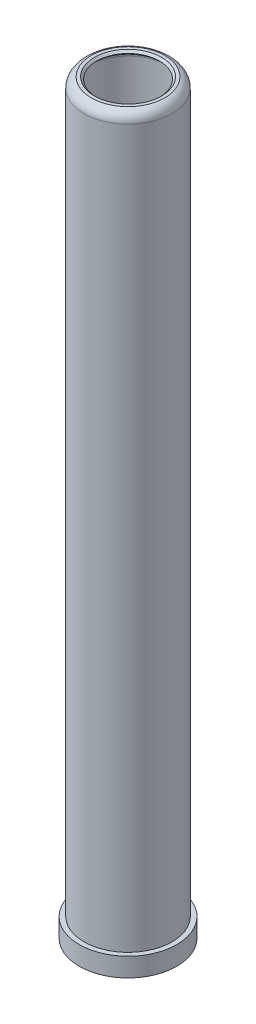
from build123d import *


with BuildPart() as part:
    # Sketch1 → Revolve1 (revolve)
    with BuildSketch(Plane.XY):
        with BuildLine():
            Line((12.5, 7), (12.5, 227.966923077))
            ThreePointArc((12.5, 227.966923077), (11.964906619, 229.258752773), (10.673076923, 229.793846154))
            Line((10.673076923, 229.793846154), (10, 230.466923077))
            Line((10, 230.466923077), (10.673076923, 231.14))
            Line((10.673076923, 231.14), (11.673076923, 231.14))
            ThreePointArc((11.673076923, 231.14), (13.355924313, 229.934344496), (14, 227.966923077))
            Line((14, 227.966923077), (14, 0))
            Line((14, 0), (15.5, 0))
            Line((15.5, 0), (15.5, -6))
            Line((15.5, -6), (14.5, -6))
            ThreePointArc((14.5, -6), (13.538055577, -2.948361096), (11, -1))
            Line((11, -1), (11, 2))
            Line((11, 2), (10, 2))
            Line((10, 2), (10, 7))
            Line((10, 7), (12.5, 7))
        make_face()
    revolve(axis=Axis((0, -1085.204253018, 0), (0, 1, 0)))


solid = part.part
